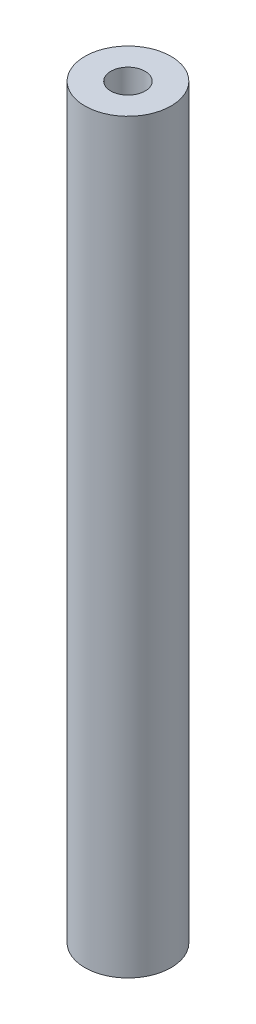
from build123d import *

# Parameters (mm, degrees)
SKETCH3_R                      = 4.7625
BOSS_EXTRUDE1_DEPTH            = 82.55
TAP_DRILL_FOR_10_24_TAP1_D     = 3.7973
TAP_DRILL_FOR_10_24_TAP1_DEPTH = 6.35
TAP_DRILL_FOR_10_24_TAP1_TIP   = 1.140824014


with BuildPart() as part:
    # Sketch3 → Boss-Extrude1 (new body)
    with BuildSketch(Plane(origin=(0, -43.50766, 0), x_dir=(1, 0, 0), z_dir=(0, 1, 0))):
        with Locations((-31.608077822, -60.718552564)):
            Circle(SKETCH3_R)
    extrude(amount=-BOSS_EXTRUDE1_DEPTH)

    # Tap Drill for #10-24 Tap1
    with Locations(Plane(origin=(0, -43.50766, 0), x_dir=(1, 0, 0), z_dir=(0, 1, 0))):
        with Locations((-31.608077822, -60.718552564)):
            Hole(TAP_DRILL_FOR_10_24_TAP1_D / 2, depth=TAP_DRILL_FOR_10_24_TAP1_DEPTH)
            with Locations((0, 0, -(TAP_DRILL_FOR_10_24_TAP1_DEPTH + TAP_DRILL_FOR_10_24_TAP1_TIP / 2))):  # 118° drill point
                Cone(0, TAP_DRILL_FOR_10_24_TAP1_D / 2, TAP_DRILL_FOR_10_24_TAP1_TIP, mode=Mode.SUBTRACT)


solid = part.part
